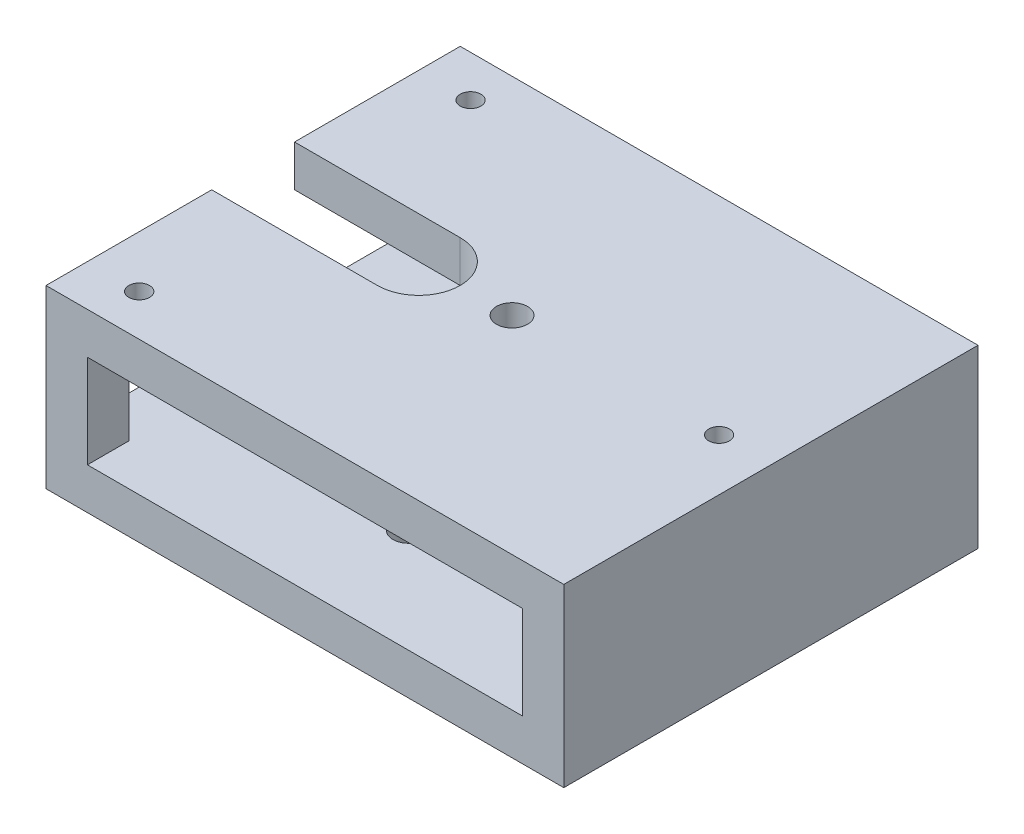
from build123d import *

# Parameters (mm, degrees)
SKETCH1_W               = 250
SKETCH1_H               = 200
BOSS_EXTRUDE1_DEPTH     = 20
BOSS_EXTRUDE2_START     = 65
SKETCH1_2_W             = 250
SKETCH1_2_H             = 200
BOSS_EXTRUDE2_DEPTH     = 20
SKETCH2_W               = 20
SKETCH2_H               = 20
BOSS_EXTRUDE3_DEPTH     = 45
SKETCH4_R               = 5
CUT_EXTRUDE1_DEPTH      = 10
SKETCH5_R               = 7.5
CUT_EXTRUDE2_DEPTH      = 75
CUT_EXTRUDE3_DEPTH      = 1
CUT_EXTRUDE3_DEPTH_BACK = 86
SKETCH7_R               = 7.5
CUT_EXTRUDE4_DEPTH      = 20
SKETCH8_W               = 160
SKETCH8_H               = 45
BOSS_EXTRUDE4_DEPTH     = 5


with BuildPart() as part:
    # Sketch1 → Boss-Extrude1 (new body)
    with BuildSketch(Plane(origin=(0, 0, 0), x_dir=(1, 0, 0), z_dir=(0, 1, 0))):
        Rectangle(SKETCH1_W, SKETCH1_H)
    extrude(amount=BOSS_EXTRUDE1_DEPTH)



with BuildPart() as body_2:
    # Sketch1_2 → Boss-Extrude2 (new body)
    with BuildSketch(Plane(origin=(0, 0, 0), x_dir=(1, 0, 0), z_dir=(0, 1, 0)).offset(BOSS_EXTRUDE2_START)):
        Rectangle(SKETCH1_2_W, SKETCH1_2_H)
    extrude(amount=BOSS_EXTRUDE2_DEPTH)


with BuildPart() as part_1:
    add(part.part)

    add(body_2.part)  # Boss-Extrude3 merges body 2
    # Sketch2 → Boss-Extrude3 (add)
    with BuildSketch(Plane(origin=(0, 20, 0), x_dir=(1, 0, 0), z_dir=(0, 1, 0))):
        with Locations((-115, -90)):
            Rectangle(SKETCH2_W, SKETCH2_H)
        with Locations((-115, 90)):
            Rectangle(SKETCH2_W, SKETCH2_H)
        with Locations((115, 90)):
            Rectangle(SKETCH2_W, SKETCH2_H)
        with Locations((115, -90)):
            Rectangle(SKETCH2_W, SKETCH2_H)
    extrude(amount=BOSS_EXTRUDE3_DEPTH)

    # Sketch4 → Cut-Extrude1 (cut)
    with BuildSketch(Plane(origin=(0, 85, 0), x_dir=(1, 0, 0), z_dir=(0, 1, 0))):
        with Locations((100, 0)):
            Circle(SKETCH4_R)
        with Locations((-100, -80)):
            Circle(SKETCH4_R)
        with Locations((-100, 80)):
            Circle(SKETCH4_R)
    extrude(amount=-CUT_EXTRUDE1_DEPTH, mode=Mode.SUBTRACT)

    # Sketch5 → Cut-Extrude2 (cut)
    with BuildSketch(Plane(origin=(0, 85, 0), x_dir=(1, 0, 0), z_dir=(0, 1, 0))):
        Circle(SKETCH5_R)
    extrude(amount=-CUT_EXTRUDE2_DEPTH, mode=Mode.SUBTRACT)

    # Sketch6 → Cut-Extrude3 (cut, two sides)
    with BuildSketch(Plane(origin=(0, 85, 0), x_dir=(1, 0, 0), z_dir=(0, 1, 0))) as cut_extrude3_sk:
        with BuildLine():
            Line((-125, 20), (-45, 20))
            ThreePointArc((-45, 20), (-25, 0), (-45, -20))
            Line((-45, -20), (-125, -20))
            Line((-125, -20), (-125, 20))
        make_face()
    extrude(amount=CUT_EXTRUDE3_DEPTH, mode=Mode.SUBTRACT)
    extrude(cut_extrude3_sk.sketch, amount=-CUT_EXTRUDE3_DEPTH_BACK, mode=Mode.SUBTRACT)

    # Sketch7 → Cut-Extrude4 (cut)
    with BuildSketch(Plane.XZ):
        with Locations((0, 50)):
            Circle(SKETCH7_R)
    extrude(amount=-CUT_EXTRUDE4_DEPTH, mode=Mode.SUBTRACT)

    # Sketch8 → Boss-Extrude4 (add)
    with BuildSketch(Plane(origin=(125, 0, 0), x_dir=(0, 0, -1), z_dir=(1, 0, 0))):
        with Locations((0, 42.5)):
            Rectangle(SKETCH8_W, SKETCH8_H)
    extrude(amount=-BOSS_EXTRUDE4_DEPTH)


solid = part_1.part
